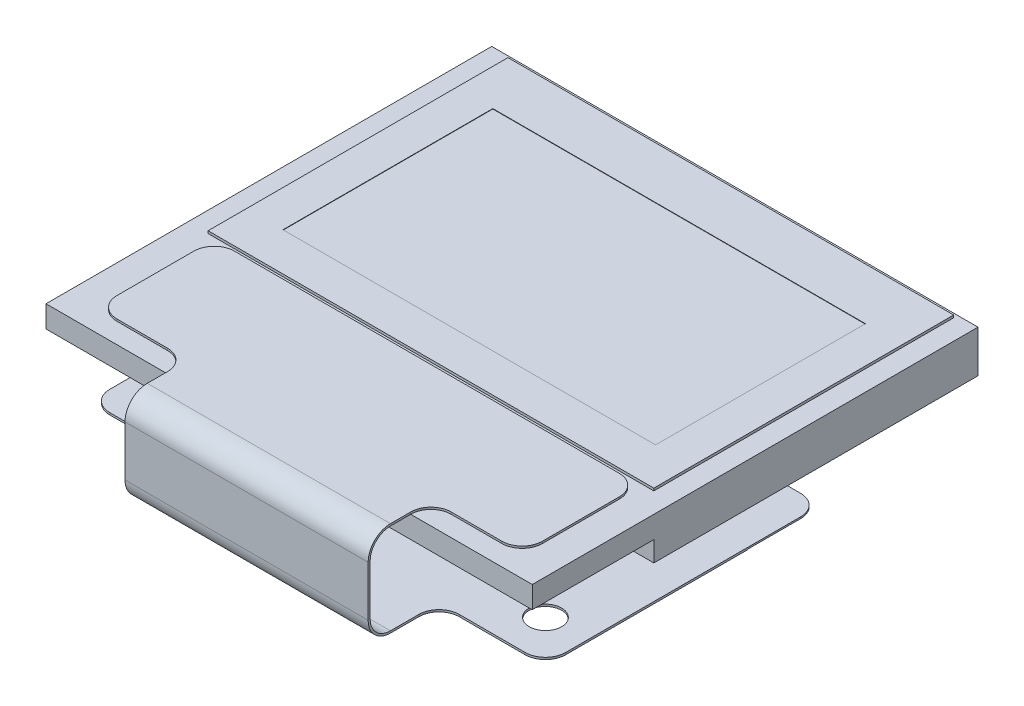
from build123d import *

# Parameters (mm, degrees)
SKETCH1_W           = 12
SKETCH1_H           = 11
BOSS_EXTRUDE1_DEPTH = 1.1
SKETCH2_W           = 12
SKETCH2_H           = 11
SKETCH2_W_2         = 11
SKETCH2_H_2         = 7.4
CUT_EXTRUDE1_DEPTH  = 0.06
SKETCH3_W           = 9.196
SKETCH3_H           = 5.18
CUT_EXTRUDE2_DEPTH  = 0.01
SKETCH4_W           = 12
SKETCH4_H           = 3
CUT_EXTRUDE3_DEPTH  = 0.5
BOSS_EXTRUDE2_DEPTH = 0.05
BOSS_EXTRUDE3_DEPTH = 3
SKETCH7_W           = 11.25
SKETCH7_H           = 6.8
SKETCH7_R           = 0.4
BOSS_EXTRUDE4_DEPTH = 0.05
SKETCH8_W           = 0.3
SKETCH8_H           = 1.8
SKETCH8_W_2         = 0.575
CUT_EXTRUDE4_DEPTH  = 0.01
SKETCH10_W          = 10.1
SKETCH10_H          = 0.05
CUT_EXTRUDE5_DEPTH  = 0.01
FILLET1_R           = 0.5


with BuildPart() as part:
    # Sketch1 → Boss-Extrude1 (new body)
    with BuildSketch(Plane(origin=(0, 0, 0), x_dir=(1, 0, 0), z_dir=(0, 1, 0))):
        Rectangle(SKETCH1_W, SKETCH1_H)
    extrude(amount=BOSS_EXTRUDE1_DEPTH)

    # Sketch2 → Cut-Extrude1 (cut)
    with BuildSketch(Plane(origin=(0, 1.1, 0), x_dir=(1, 0, 0), z_dir=(0, 1, 0))):
        Rectangle(SKETCH2_W, SKETCH2_H)
        with Locations((0, 1.7)):
            Rectangle(SKETCH2_W_2, SKETCH2_H_2, mode=Mode.SUBTRACT)
    extrude(amount=-CUT_EXTRUDE1_DEPTH, mode=Mode.SUBTRACT)

    # Sketch3 → Cut-Extrude2 (cut)
    with BuildSketch(Plane(origin=(0, 1.1, 0), x_dir=(1, 0, 0), z_dir=(0, 1, 0))):
        with Locations((0, 1.535)):
            Rectangle(SKETCH3_W, SKETCH3_H)
    extrude(amount=-CUT_EXTRUDE2_DEPTH, mode=Mode.SUBTRACT)

    # Sketch4 → Cut-Extrude3 (cut)
    with BuildSketch(Plane.XZ):
        with Locations((0, 4)):
            Rectangle(SKETCH4_W, SKETCH4_H)
    extrude(amount=-CUT_EXTRUDE3_DEPTH, mode=Mode.SUBTRACT)

    # Sketch5 → Boss-Extrude2 (add)
    with BuildSketch(Plane(origin=(0, 1.04, 0), x_dir=(1, 0, 0), z_dir=(0, 1, 0))):
        with BuildLine():
            Line((-4.75, -2.1), (4.75, -2.1))
            ThreePointArc((4.75, -2.1), (5.103553391, -2.246446609), (5.25, -2.6))
            Line((5.25, -2.6), (5.25, -4.5))
            ThreePointArc((5.25, -4.5), (5.103553391, -4.853553391), (4.75, -5))
            Line((4.75, -5), (3.5, -5))
            ThreePointArc((3.5, -5), (3.146446609, -5.146446609), (3, -5.5))
            Line((3, -5.5), (3, -6))
            Line((3, -6), (-3, -6))
            Line((-3, -6), (-3, -5.5))
            ThreePointArc((-3, -5.5), (-3.146446609, -5.146446609), (-3.5, -5))
            Line((-3.5, -5), (-4.75, -5))
            ThreePointArc((-4.75, -5), (-5.103553391, -4.853553391), (-5.25, -4.5))
            Line((-5.25, -4.5), (-5.25, -2.6))
            ThreePointArc((-5.25, -2.6), (-5.103553391, -2.246446609), (-4.75, -2.1))
        make_face()
    extrude(amount=BOSS_EXTRUDE2_DEPTH)

    # Sketch6 → Boss-Extrude3 (add, symmetric)
    with BuildSketch(Plane(origin=(0, 0, 0), x_dir=(0, 0, -1), z_dir=(1, 0, 0))):
        with BuildLine():
            Line((-6.5, 0.54), (-6.5, -0.7))
            ThreePointArc((-6.5, -0.7), (-6.353553391, -1.053553391), (-6, -1.2))
            Line((-6, -1.2), (2, -1.2))
            Line((2, -1.2), (2, -1.25))
            Line((2, -1.25), (-6, -1.25))
            ThreePointArc((-6, -1.25), (-6.38890873, -1.08890873), (-6.55, -0.7))
            Line((-6.55, -0.7), (-6.55, 0.54))
            ThreePointArc((-6.55, 0.54), (-6.38890873, 0.92890873), (-6, 1.09))
            Line((-6, 1.09), (-6, 1.04))
            ThreePointArc((-6, 1.04), (-6.353553391, 0.893553391), (-6.5, 0.54))
        make_face()
    extrude(amount=BOSS_EXTRUDE3_DEPTH, both=True)

    # Sketch7 → Boss-Extrude4 (add)
    with BuildSketch(Plane.XZ.offset(1.25)):
        with Locations((0, 1.4)):
            Rectangle(SKETCH7_W, SKETCH7_H)
        with Locations((-4.625, 3.8)):
            Circle(SKETCH7_R, mode=Mode.SUBTRACT)
        with Locations((4.625, 3.8)):
            Circle(SKETCH7_R, mode=Mode.SUBTRACT)
    extrude(amount=-BOSS_EXTRUDE4_DEPTH)

    # Sketch8 → Cut-Extrude4 (cut)
    with BuildSketch(Plane.XZ.offset(1.25)):
        with Locations((0, -1.1)):
            Rectangle(SKETCH8_W, SKETCH8_H)
        with Locations((0.65, -1.1)):
            Rectangle(SKETCH8_W, SKETCH8_H)
        with Locations((1.3, -1.1)):
            Rectangle(SKETCH8_W, SKETCH8_H)
        with Locations((1.95, -1.1)):
            Rectangle(SKETCH8_W, SKETCH8_H)
        with Locations((2.6, -1.1)):
            Rectangle(SKETCH8_W, SKETCH8_H)
        with Locations((3.25, -1.1)):
            Rectangle(SKETCH8_W, SKETCH8_H)
        with Locations((3.9, -1.1)):
            Rectangle(SKETCH8_W, SKETCH8_H)
        with Locations((4.55, -1.1)):
            Rectangle(SKETCH8_W, SKETCH8_H)
        with Locations((-4.55, -1.1)):
            Rectangle(SKETCH8_W, SKETCH8_H)
        with Locations((-3.9, -1.1)):
            Rectangle(SKETCH8_W, SKETCH8_H)
        with Locations((-3.25, -1.1)):
            Rectangle(SKETCH8_W, SKETCH8_H)
        with Locations((-2.6, -1.1)):
            Rectangle(SKETCH8_W, SKETCH8_H)
        with Locations((-1.95, -1.1)):
            Rectangle(SKETCH8_W, SKETCH8_H)
        with Locations((-1.3, -1.1)):
            Rectangle(SKETCH8_W, SKETCH8_H)
        with Locations((-0.65, -1.1)):
            Rectangle(SKETCH8_W, SKETCH8_H)
        with Locations((5.3375, -1.1)):
            Rectangle(SKETCH8_W_2, SKETCH8_H)
        with Locations((-5.3375, -1.1)):
            Rectangle(SKETCH8_W_2, SKETCH8_H)
    extrude(amount=-CUT_EXTRUDE4_DEPTH, mode=Mode.SUBTRACT)

    # Sketch10 → Cut-Extrude5 (cut)
    with BuildSketch(Plane.XZ.offset(1.25)):
        with Locations((0, -0.225)):
            Rectangle(SKETCH10_W, SKETCH10_H)
    extrude(amount=-CUT_EXTRUDE5_DEPTH, mode=Mode.SUBTRACT)

    # Fillet1
    fillet1_edges = [part.edges().sort_by_distance(p)[0] for p in [
        (5.625, -1.22, -2),
        (-5.625, -1.225, 4.8),
        (5.625, -1.225, 4.8),
        (3, -1.225, 4.8),
        (-3, -1.225, 4.8),
        (-5.625, -1.22, -2),
    ]]
    fillet(fillet1_edges, radius=FILLET1_R)


solid = part.part
